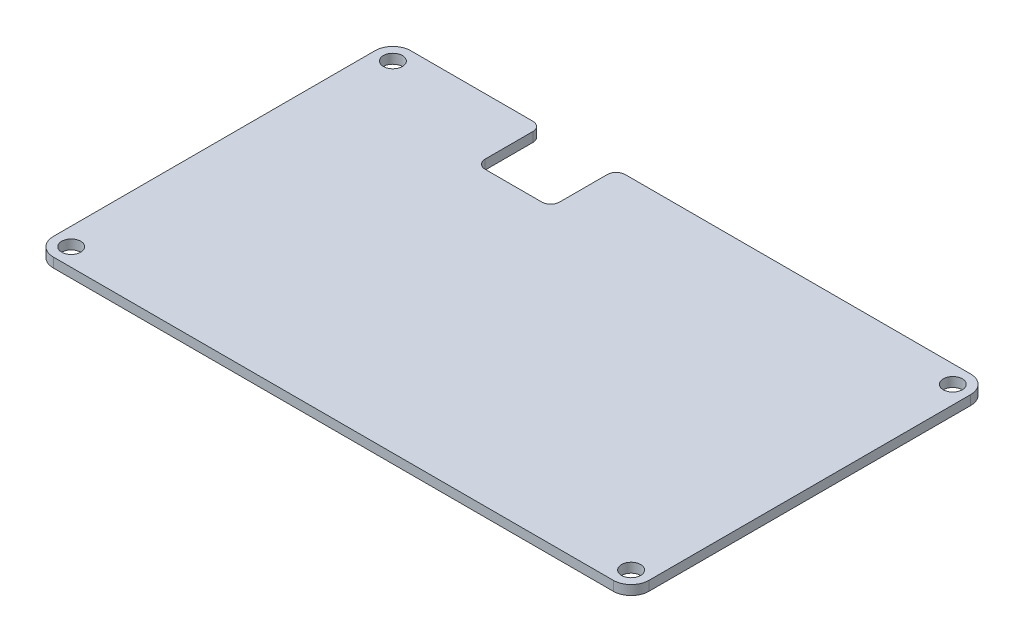
from build123d import *

# Parameters (mm, degrees)
SKETCH_1_W          = 100
SKETCH_1_H          = 60
EXTRUDE_1_DEPTH     = 1.6
SKETCH_2_R          = 1.6
CUT_EXTRUDE_1_DEPTH = 2.6
SKETCH_3_W          = 12.5
SKETCH_3_H          = 11
CUT_EXTRUDE_2_DEPTH = 2.6
FILLET_1_R          = 3
FILLET_2_R          = 1.5


with BuildPart() as part:
    # 草图1 → 凸台-拉伸1 (new body)
    with BuildSketch(Plane(origin=(0, 0, 0), x_dir=(1, 0, 0), z_dir=(0, 1, 0))):
        Rectangle(SKETCH_1_W, SKETCH_1_H)
    extrude(amount=EXTRUDE_1_DEPTH)

    # 草图2 → 切除-拉伸1 (cut, through all)
    with BuildSketch(Plane(origin=(0, 1.6, 0), x_dir=(1, 0, 0), z_dir=(0, 1, 0))):
        with Locations((-47, 27)):
            Circle(SKETCH_2_R)
        with Locations((47, 27)):
            Circle(SKETCH_2_R)
        with Locations((47, -27)):
            Circle(SKETCH_2_R)
        with Locations((-47, -27)):
            Circle(SKETCH_2_R)
    extrude(amount=-CUT_EXTRUDE_1_DEPTH, mode=Mode.SUBTRACT)

    # 草图3 → 切除-拉伸2 (cut, through all)
    with BuildSketch(Plane(origin=(0, 1.6, 0), x_dir=(1, 0, 0), z_dir=(0, 1, 0))):
        with Locations((-18.75, 24.5)):
            Rectangle(SKETCH_3_W, SKETCH_3_H)
    extrude(amount=-CUT_EXTRUDE_2_DEPTH, mode=Mode.SUBTRACT)

    # 圆角1
    fillet_1_edges = [part.edges().sort_by_distance(p)[0] for p in [
        (-50, 0.8, 30),
        (-50, 0.8, -30),
        (50, 0.8, -30),
        (50, 0.8, 30),
    ]]
    fillet(fillet_1_edges, radius=FILLET_1_R)

    # 圆角2
    fillet_2_edges = [part.edges().sort_by_distance(p)[0] for p in [
        (-25, 0.8, -19),
        (-25, 0.8, -30),
        (-12.5, 0.8, -30),
        (-12.5, 0.8, -19),
    ]]
    fillet(fillet_2_edges, radius=FILLET_2_R)


solid = part.part
